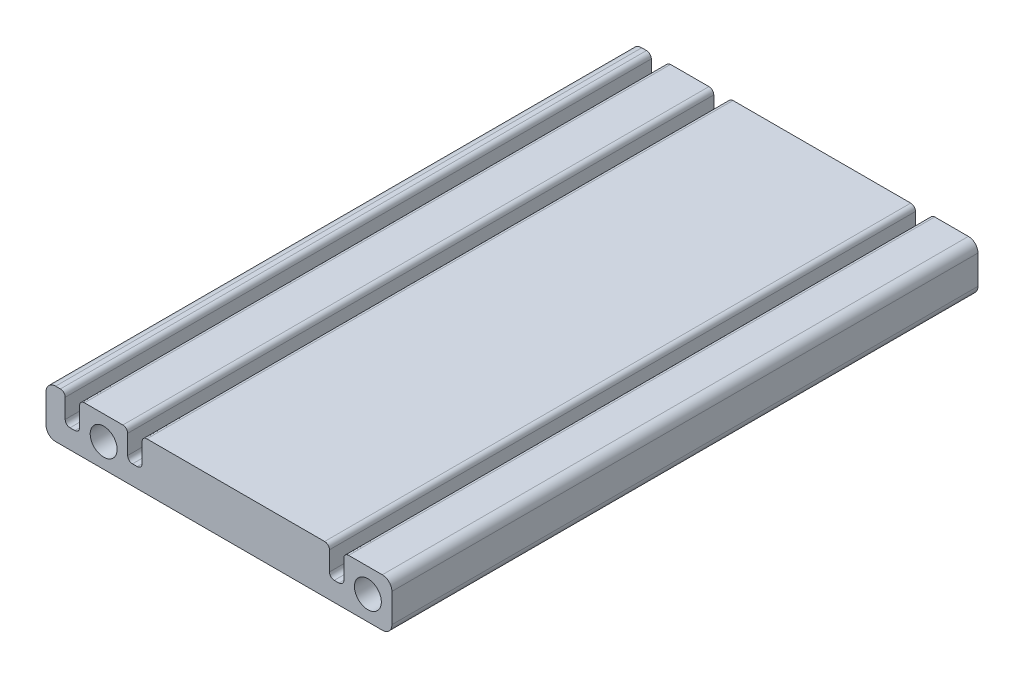
from build123d import *

# Parameters (mm, degrees)
ESQUISSE1_R        = 2.8
BOSS_EXTRU_1_DEPTH = 122
CONG_1_R           = 1
CONG_2_R           = 2


with BuildPart() as part:
    # Esquisse1 → Boss.-Extru.1 (new body)
    with BuildSketch(Plane.XY):
        Polygon((-35.89112663, -3.089603204), (-35.89112663, 6.910396796), (-31.89112663, 6.910396796), (-31.89112663, 0.910396796), (-28.89112663, 0.910396796), (-28.89112663, 6.910396796), (-18.89112663, 6.910396796), (-18.89112663, 0.910396796), (-15.89112663, 0.910396796), (-15.89112663, 6.910396796), (23.10887337, 6.910396796), (23.10887337, 0.910396796), (26.10887337, 0.910396796), (26.10887337, 6.910396796), (36.10887337, 6.910396796), (36.10887337, -3.089603204), align=None)
        with Locations((-23.89112663, 1.910396796)):
            Circle(ESQUISSE1_R, mode=Mode.SUBTRACT)
        with Locations((31.10887337, 1.910396796)):
            Circle(ESQUISSE1_R, mode=Mode.SUBTRACT)
    extrude(amount=BOSS_EXTRU_1_DEPTH)

    # Congé1
    cong_1_edges = [part.edges().sort_by_distance(p)[0] for p in [
        (-31.89112663, 0.910396796, 61),
        (-31.89112663, 6.910396796, 61),
        (26.10887337, 6.910396796, 61),
        (26.10887337, 0.910396796, 61),
        (23.10887337, 0.910396796, 61),
        (23.10887337, 6.910396796, 61),
        (-15.89112663, 6.910396796, 61),
        (-15.89112663, 0.910396796, 61),
        (-18.89112663, 0.910396796, 61),
        (-18.89112663, 6.910396796, 61),
        (-28.89112663, 6.910396796, 61),
        (-28.89112663, 0.910396796, 61),
    ]]
    fillet(cong_1_edges, radius=CONG_1_R)

    # Congé2
    cong_2_edges = [part.edges().sort_by_distance(p)[0] for p in [
        (-35.89112663, 6.910396796, 61),
        (-35.89112663, -3.089603204, 61),
        (36.10887337, -3.089603204, 61),
        (36.10887337, 6.910396796, 61),
    ]]
    fillet(cong_2_edges, radius=CONG_2_R)


solid = part.part
